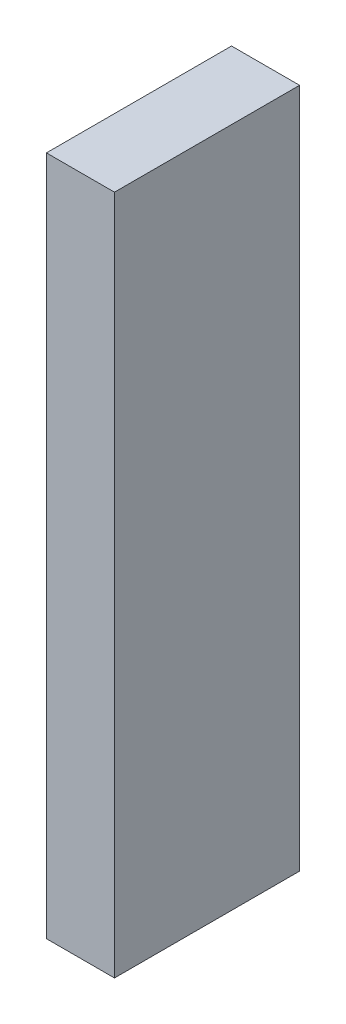
from build123d import *

# Parameters (mm, degrees)
SKETCH1_W           = 8.636
SKETCH1_H           = 31.75
BOSS_EXTRUDE1_DEPTH = 3.175


with BuildPart() as part:
    # Sketch1 → Boss-Extrude1 (new body)
    with BuildSketch(Plane(origin=(0, 0, 0), x_dir=(0, 0, -1), z_dir=(1, 0, 0))):
        Rectangle(SKETCH1_W, SKETCH1_H)
    extrude(amount=BOSS_EXTRUDE1_DEPTH)


solid = part.part
